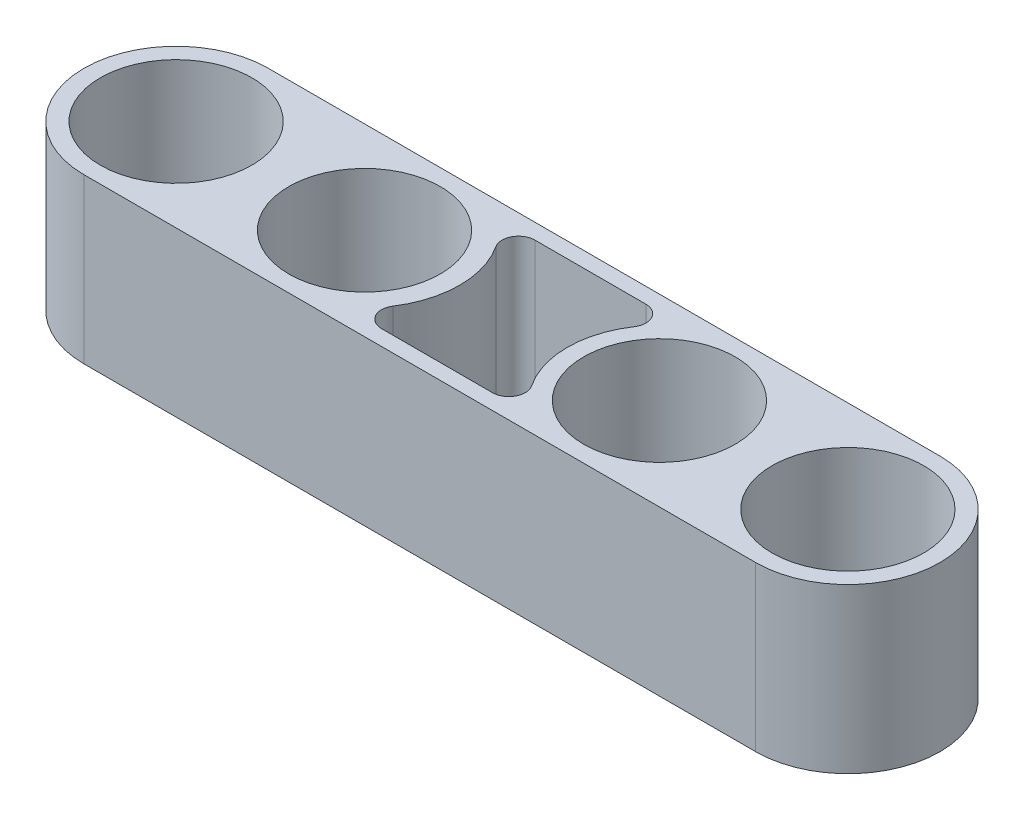
from build123d import *

# Parameters (mm, degrees)
SKETCH3_R           = 9.25
BOSS_EXTRUDE1_DEPTH = 20


with BuildPart() as part:
    # Sketch3 → Boss-Extrude1 (new body)
    with BuildSketch(Plane(origin=(0, 0, 0), x_dir=(1, 0, 0), z_dir=(0, 1, 0))):
        with BuildLine():
            Line((-41, -11.25), (41, -11.25))
            ThreePointArc((41, -11.25), (52.25, 0), (41, 11.25))
            Line((41, 11.25), (-41, 11.25))
            ThreePointArc((-41, 11.25), (-52.25, 0), (-41, -11.25))
        make_face()
        with Locations((-41, 0)):
            Circle(SKETCH3_R, mode=Mode.SUBTRACT)
        with Locations((-18, 0)):
            Circle(SKETCH3_R, mode=Mode.SUBTRACT)
        with Locations((18, 0)):
            Circle(SKETCH3_R, mode=Mode.SUBTRACT)
        with Locations((41, 0)):
            Circle(SKETCH3_R, mode=Mode.SUBTRACT)
        with BuildLine():
            ThreePointArc((-8.243682204, -6.270576132), (-6.383696467, 0), (-8.243682204, 6.270576132))
            ThreePointArc((-8.243682204, 6.270576132), (-8.325149731, 8.314769866), (-6.567157985, 9.361111111))
            Line((-6.567157985, 9.361111111), (6.982897694, 9.361111111))
            ThreePointArc((6.982897694, 9.361111111), (8.746731902, 8.303920153), (8.645856533, 6.25))
            ThreePointArc((8.645856533, 6.25), (6.75, 0), (8.645856533, -6.25))
            ThreePointArc((8.645856533, -6.25), (8.746731902, -8.303920153), (6.982897694, -9.361111111))
            Line((6.982897694, -9.361111111), (-6.567157985, -9.361111111))
            ThreePointArc((-6.567157985, -9.361111111), (-8.325149731, -8.314769866), (-8.243682204, -6.270576132))
        make_face(mode=Mode.SUBTRACT)
    extrude(amount=BOSS_EXTRUDE1_DEPTH)


solid = part.part
